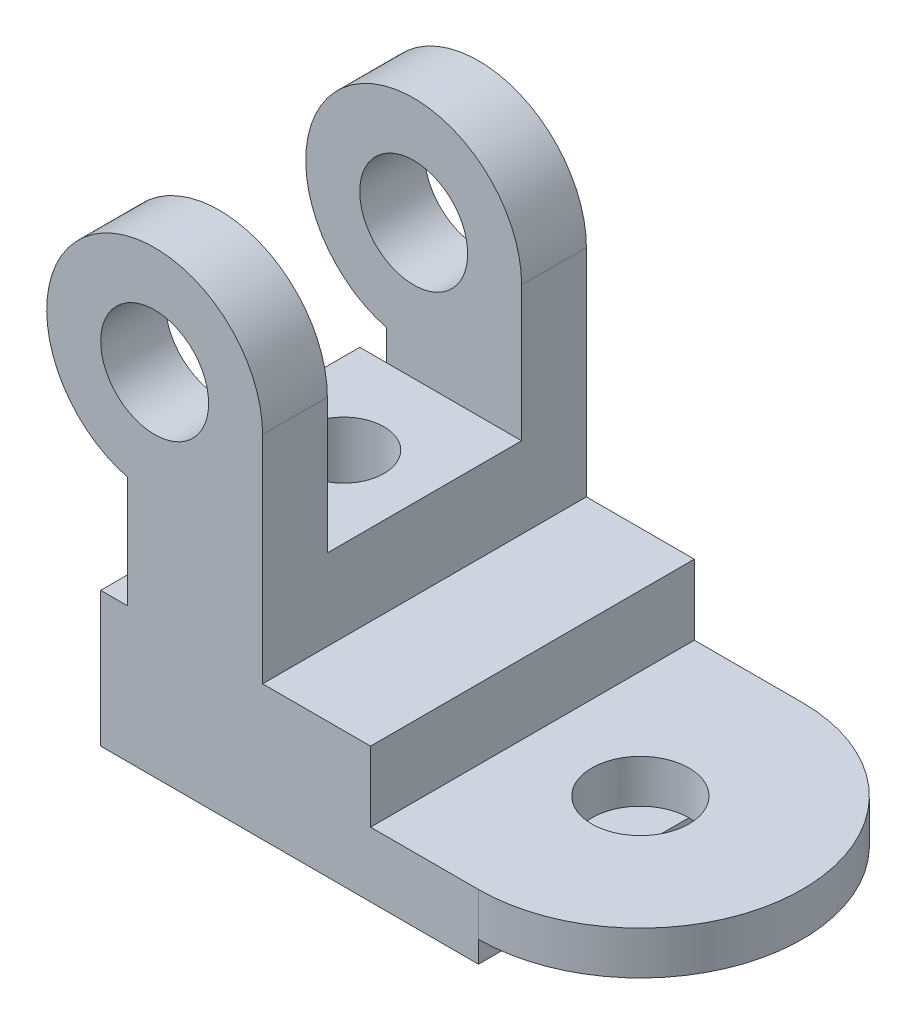
from build123d import *

# Parameters (mm, degrees)
SKETCH1_R           = 10
BOSS_EXTRUDE1_DEPTH = 30
BOSS_EXTRUDE3_DEPTH = 8
SKETCH4_R           = 9
CUT_EXTRUDE5_DEPTH  = 8
SKETCH7_W           = 36
SKETCH7_H           = 64.778485803
CUT_EXTRUDE6_DEPTH  = 41
SKETCH8_W           = 30
SKETCH8_H           = 36
BOSS_EXTRUDE5_DEPTH = 15
SKETCH9_R           = 7.5
CUT_EXTRUDE8_DEPTH  = 41


with BuildPart() as part:
    # Sketch1 → Boss-Extrude1 (new body, symmetric)
    with BuildSketch(Plane.XY):
        with BuildLine():
            Line((-35, 25), (-35, 0))
            Line((-35, 0), (35, 0))
            Line((35, 0), (35, 12))
            Line((35, 12), (15, 12))
            Line((15, 12), (15, 25))
            Line((15, 25), (-5, 25))
            Line((-5, 25), (-5, 40))
            Line((-5, 40), (-5, 65))
            ThreePointArc((-5, 65), (-37.247448714, 80.811388301), (-30, 45.635083269))
            Line((-30, 45.635083269), (-30, 40))
            Line((-30, 40), (-30, 25))
            Line((-30, 25), (-35, 25))
        make_face()
        with Locations((-25, 65)):
            Circle(SKETCH1_R, mode=Mode.SUBTRACT)
    extrude(amount=BOSS_EXTRUDE1_DEPTH, both=True)

    # Sketch3 → Boss-Extrude3 (add)
    with BuildSketch(Plane(origin=(0, 12, 0), x_dir=(1, 0, 0), z_dir=(0, 1, 0))):
        with BuildLine():
            Line((15, 30), (35, 30))
            ThreePointArc((35, 30), (65, 0), (35, -30))
            Line((35, -30), (15, -30))
            Line((15, -30), (15, 30))
        make_face()
    extrude(amount=-BOSS_EXTRUDE3_DEPTH)

    # Sketch4 → Cut-Extrude5 (cut)
    with BuildSketch(Plane(origin=(0, 12, 0), x_dir=(1, 0, 0), z_dir=(0, 1, 0))):
        with Locations((35, 0)):
            Circle(SKETCH4_R)
    extrude(amount=-CUT_EXTRUDE5_DEPTH, mode=Mode.SUBTRACT)

    # Sketch7 → Cut-Extrude6 (cut, through all)
    with BuildSketch(Plane(origin=(-5, 0, 0), x_dir=(0, 0, -1), z_dir=(1, 0, 0))):
        with Locations((0, 72.389242902)):
            Rectangle(SKETCH7_W, SKETCH7_H)
    extrude(amount=-CUT_EXTRUDE6_DEPTH, mode=Mode.SUBTRACT)

    # Sketch8 → Boss-Extrude5 (add)
    with BuildSketch(Plane(origin=(0, 40, 0), x_dir=(1, 0, 0), z_dir=(0, 1, 0))):
        with Locations((-20, 0)):
            Rectangle(SKETCH8_W, SKETCH8_H)
    extrude(amount=-BOSS_EXTRUDE5_DEPTH)

    # Sketch9 → Cut-Extrude8 (cut, through all)
    with BuildSketch(Plane(origin=(0, 40, 0), x_dir=(1, 0, 0), z_dir=(0, 1, 0))):
        with Locations((-20, 0)):
            Circle(SKETCH9_R)
    extrude(amount=-CUT_EXTRUDE8_DEPTH, mode=Mode.SUBTRACT)


solid = part.part
